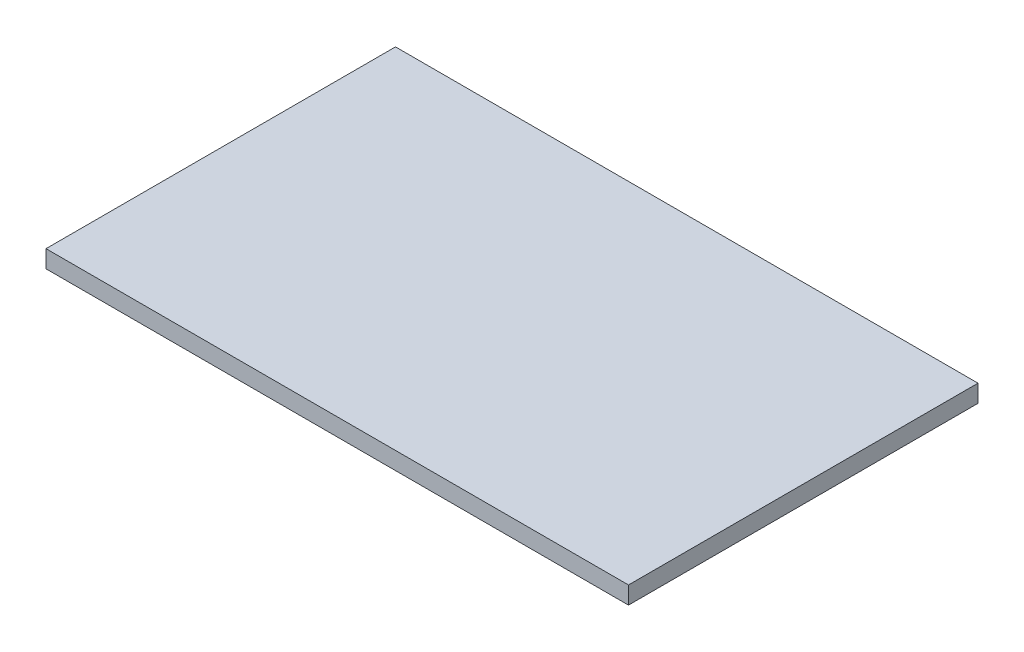
from build123d import *

# Parameters (mm, degrees)
SKETCH1_W           = 10
SKETCH1_H           = 6
BOSS_EXTRUDE1_DEPTH = 0.3


with BuildPart() as part:
    # Sketch1 → Boss-Extrude1 (new body)
    with BuildSketch(Plane(origin=(0, 0, 0), x_dir=(1, 0, 0), z_dir=(0, 1, 0))):
        with Locations((5, 3)):
            Rectangle(SKETCH1_W, SKETCH1_H)
    extrude(amount=BOSS_EXTRUDE1_DEPTH)


solid = part.part
